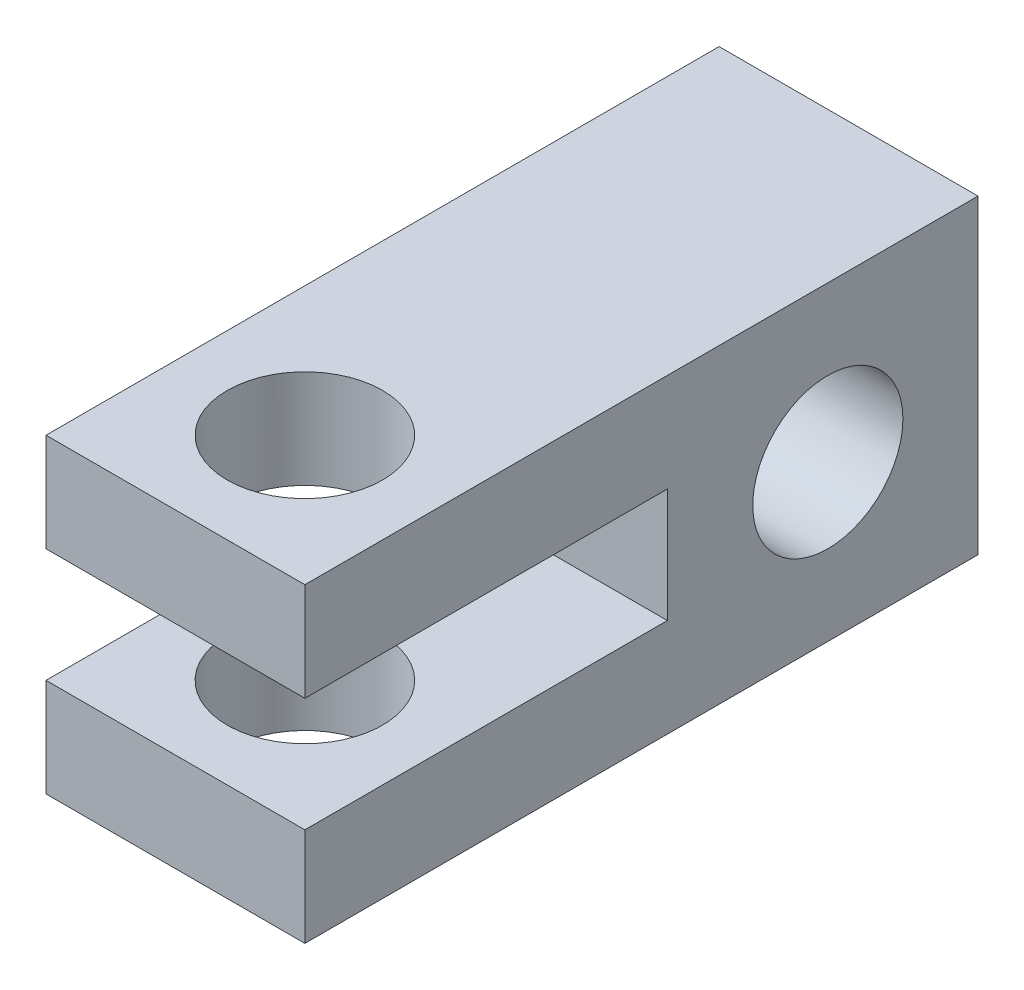
from build123d import *

# Parameters (mm, degrees)
SKETCH1_W               = 6.35
SKETCH1_H               = 16.51
SKETCH1_R               = 1.905
BOSS_EXTRUDE1_DEPTH     = 7.62
SKETCH2_W               = 6.35
SKETCH2_H               = 2.794
CUT_EXTRUDE1_DEPTH      = 1
CUT_EXTRUDE1_DEPTH_BACK = 8.89
SKETCH4_R               = 1.8415
CUT_EXTRUDE2_DEPTH      = 7.35


with BuildPart() as part:
    # Sketch1 → Boss-Extrude1 (new body)
    with BuildSketch(Plane(origin=(0, 0, 0), x_dir=(1, 0, 0), z_dir=(0, 1, 0))):
        with Locations((3.175, 8.255)):
            Rectangle(SKETCH1_W, SKETCH1_H)
        with Locations((3.175, 3.175)):
            Circle(SKETCH1_R, mode=Mode.SUBTRACT)
    extrude(amount=BOSS_EXTRUDE1_DEPTH)

    # Sketch2 → Cut-Extrude1 (cut, two sides)
    with BuildSketch(Plane.XY) as cut_extrude1_sk:
        with Locations((3.175, 3.81)):
            Rectangle(SKETCH2_W, SKETCH2_H)
    extrude(amount=CUT_EXTRUDE1_DEPTH, mode=Mode.SUBTRACT)
    extrude(cut_extrude1_sk.sketch, amount=-CUT_EXTRUDE1_DEPTH_BACK, mode=Mode.SUBTRACT)

    # Sketch4 → Cut-Extrude2 (cut, through all)
    with BuildSketch(Plane(origin=(6.35, 0, 0), x_dir=(0, 0, -1), z_dir=(1, 0, 0))):
        with Locations((12.827, 3.81)):
            Circle(SKETCH4_R)
    extrude(amount=-CUT_EXTRUDE2_DEPTH, mode=Mode.SUBTRACT)


solid = part.part
